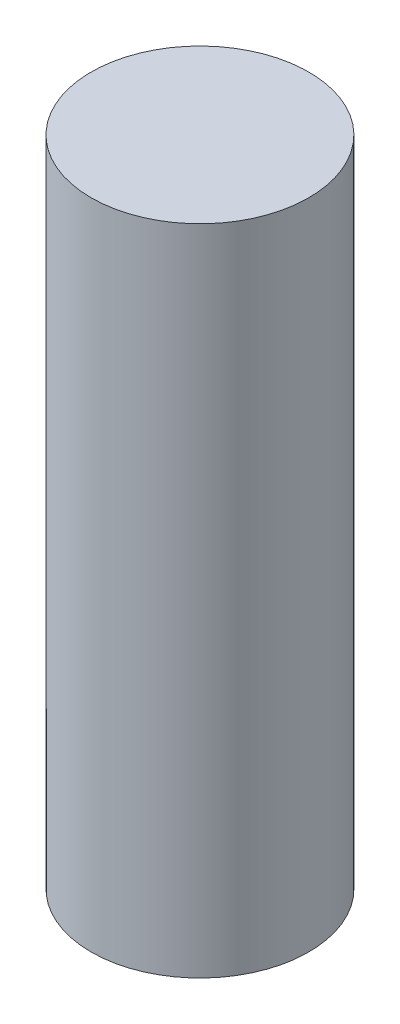
from build123d import *

# Parameters (mm, degrees)
SKETCH1_R           = 1
BOSS_EXTRUDE1_DEPTH = 6


with BuildPart() as part:
    # Sketch1 → Boss-Extrude1 (new body)
    with BuildSketch(Plane(origin=(0, 0, 0), x_dir=(1, 0, 0), z_dir=(0, 1, 0))):
        Circle(SKETCH1_R)
    extrude(amount=BOSS_EXTRUDE1_DEPTH)


solid = part.part
